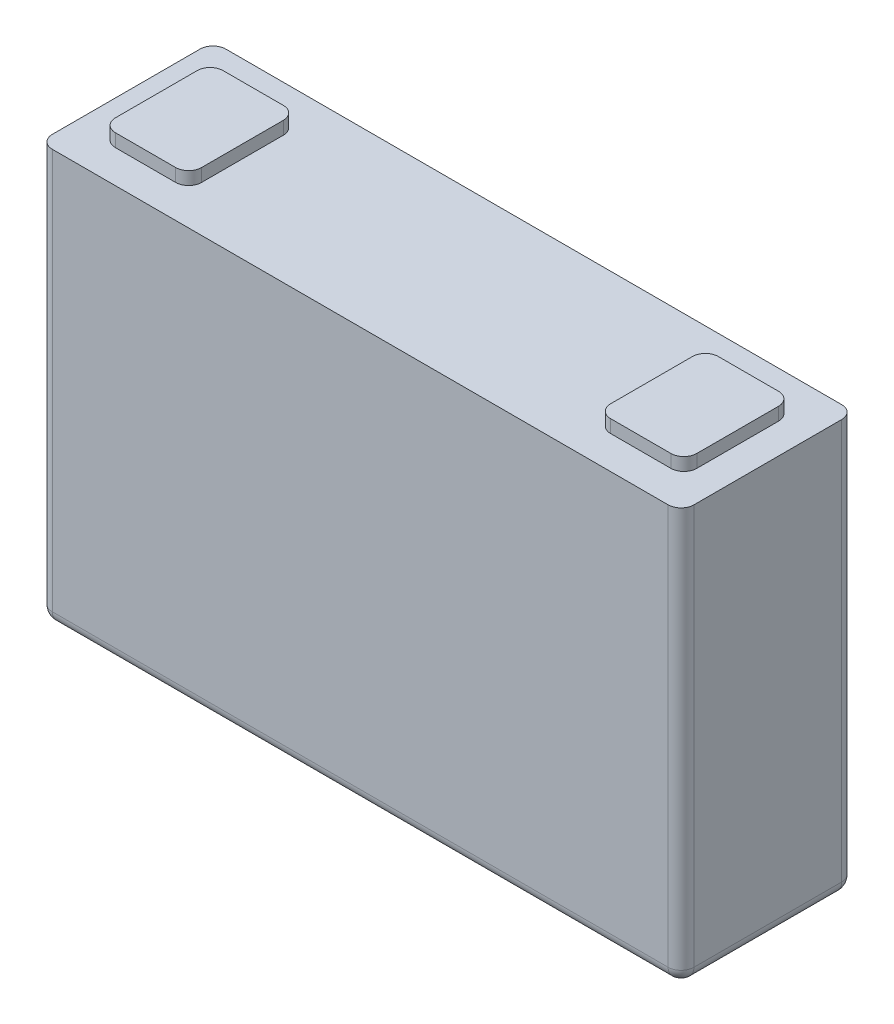
from build123d import *

# Parameters (mm, degrees)
SKETCH1_W           = 149
SKETCH1_H           = 96
BOSS_EXTRUDE1_DEPTH = 20.15
SKETCH2_W           = 20
SKETCH2_H           = 25
BOSS_EXTRUDE2_DEPTH = 3
FILLET1_R           = 3
FILLET2_R           = 3
FILLET3_R           = 3


with BuildPart() as part:
    # Sketch1 → Boss-Extrude1 (new body, symmetric)
    with BuildSketch(Plane.XY):
        Rectangle(SKETCH1_W, SKETCH1_H)
    extrude(amount=BOSS_EXTRUDE1_DEPTH, both=True)

    # Sketch2 → Boss-Extrude2 (add, symmetric)
    with BuildSketch(Plane(origin=(0, 48, 0), x_dir=(1, 0, 0), z_dir=(0, 1, 0))):
        with Locations((-57.5, 0)):
            Rectangle(SKETCH2_W, SKETCH2_H)
        with Locations((57.5, 0)):
            Rectangle(SKETCH2_W, SKETCH2_H)
    extrude(amount=BOSS_EXTRUDE2_DEPTH, both=True)

    # Fillet1
    fillet1_edges = [part.edges().sort_by_distance(p)[0] for p in [
        (74.5, 0, 20.15),
        (-74.5, 0, 20.15),
        (74.5, 0, -20.15),
        (-74.5, 0, -20.15),
    ]]
    fillet(fillet1_edges, radius=FILLET1_R)

    # Fillet2
    fillet2_edges = [part.edges().sort_by_distance(p)[0] for p in [
        (0, -48, 20.15),
        (0, -48, -20.15),
        (74.5, -48, 0),
        (-74.5, -48, 0),
        (73.621320344, -48, 19.271320344),
        (73.621320344, -48, -19.271320344),
        (-73.621320344, -48, -19.271320344),
        (-73.621320344, -48, 19.271320344),
    ]]
    fillet(fillet2_edges, radius=FILLET2_R)

    # Fillet3
    fillet3_edges = [part.edges().sort_by_distance(p)[0] for p in [
        (-67.5, 49.5, -12.5),
        (-67.5, 49.5, 12.5),
        (-47.5, 49.5, 12.5),
        (-47.5, 49.5, -12.5),
        (67.5, 49.5, 12.5),
        (67.5, 49.5, -12.5),
        (47.5, 49.5, -12.5),
        (47.5, 49.5, 12.5),
    ]]
    fillet(fillet3_edges, radius=FILLET3_R)


solid = part.part
